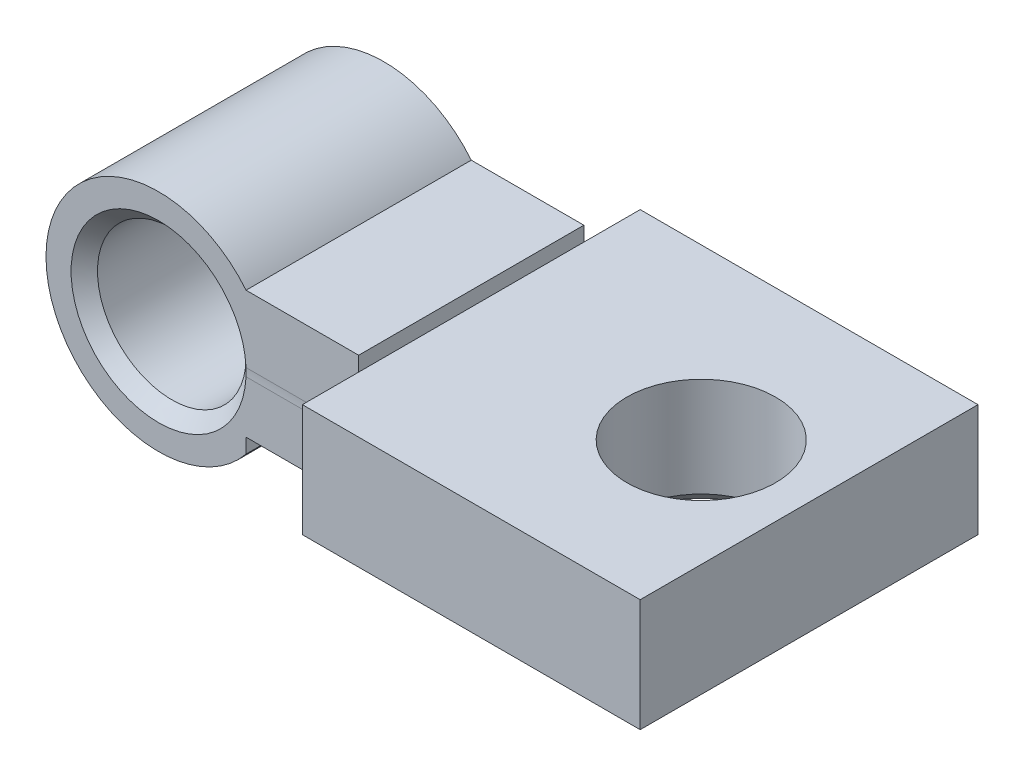
from build123d import *

# Parameters (mm, degrees)
SKETCH_1_R                      = 5
EXTRUDE_1_DEPTH                 = 10
HOLE_WIZARD_G1_16_1_D           = 6.6
HOLE_WIZARD_G1_16_1_DEPTH       = 50
HOLE_WIZARD_G1_16_1_CSINK_D     = 7.773
HOLE_WIZARD_G1_16_1_CSINK_ANGLE = 90
HOLE_WIZARD_G1_16_1_TIP         = 1.982840043
SKETCH_4_W                      = 1.792487356
SKETCH_4_H                      = 9.243284927
CUT_EXTRUDE_1_DEPTH             = 10
EXTRUDE_2_DEPTH                 = 5
SKETCH_6_W                      = 15
SKETCH_6_H                      = 5
EXTRUDE_3_DEPTH                 = 15
HOLE_WIZARD_G1_16_2_D           = 6.6
HOLE_WIZARD_G1_16_2_DEPTH       = 50
HOLE_WIZARD_G1_16_2_CSINK_D     = 7.773
HOLE_WIZARD_G1_16_2_CSINK_ANGLE = 90
HOLE_WIZARD_G1_16_2_TIP         = 1.982840043


with BuildPart() as part:
    # 草图1 → 凸台-拉伸1 (new body)
    with BuildSketch(Plane.XY):
        Circle(SKETCH_1_R)
    extrude(amount=EXTRUDE_1_DEPTH)

    # G1/16 螺纹孔1
    with Locations(Plane.XY.offset(10)):
        with Locations((0, 0)):
            CounterSinkHole(HOLE_WIZARD_G1_16_1_D / 2, HOLE_WIZARD_G1_16_1_CSINK_D / 2, depth=HOLE_WIZARD_G1_16_1_DEPTH, counter_sink_angle=HOLE_WIZARD_G1_16_1_CSINK_ANGLE)
            with Locations((0, 0, -(HOLE_WIZARD_G1_16_1_DEPTH + HOLE_WIZARD_G1_16_1_TIP / 2))):  # 118° drill point
                Cone(0, HOLE_WIZARD_G1_16_1_D / 2, HOLE_WIZARD_G1_16_1_TIP, mode=Mode.SUBTRACT)

    # 草图4 → 切除-拉伸1 (cut)
    with BuildSketch(Plane.XY.offset(10)):
        with Locations((4.778713525, -1.471019051)):
            Rectangle(SKETCH_4_W, SKETCH_4_H)
    extrude(amount=-CUT_EXTRUDE_1_DEPTH, mode=Mode.SUBTRACT)

    # 草图5 → 凸台-拉伸2 (add)
    with BuildSketch(Plane(origin=(3.882469847, 0, 0), x_dir=(0, 0, -1), z_dir=(1, 0, 0))):
        with BuildLine():
            Line((-10, -0.176946718), (-10, -2.5))
            Line((-10, -2.5), (0, -2.5))
            Line((0, -2.5), (0, 3.150623413))
            Line((0, 3.150623413), (-10, 3.150623413))
            Line((-10, 3.150623413), (-10, 0.176946718))
            add(Edge.make_bspline(
                [(-10, 0.176946718), (-9.991943872, 0), (-10, -0.176946718)],
                knots=[-0.045560049, -0.045560049, -0.045560049, 0.045560049, 0.045560049, 0.045560049], degree=2, weights=[1, 1.001038039, 1]))
        make_face()
    extrude(amount=EXTRUDE_2_DEPTH)

    # 草图6 → 凸台-拉伸3 (add)
    with BuildSketch(Plane(origin=(8.882469847, 0, 0), x_dir=(0, 0, -1), z_dir=(1, 0, 0))):
        with Locations((-5, 0)):
            Rectangle(SKETCH_6_W, SKETCH_6_H)
    extrude(amount=EXTRUDE_3_DEPTH)

    # G1/16 螺纹孔2
    with Locations(Plane(origin=(0, -2.5, 0), x_dir=(-1, 0, 0), z_dir=(0, -1, 0))):
        with Locations((-19.093145461, -5)):
            CounterSinkHole(HOLE_WIZARD_G1_16_2_D / 2, HOLE_WIZARD_G1_16_2_CSINK_D / 2, depth=HOLE_WIZARD_G1_16_2_DEPTH, counter_sink_angle=HOLE_WIZARD_G1_16_2_CSINK_ANGLE)
            with Locations((0, 0, -(HOLE_WIZARD_G1_16_2_DEPTH + HOLE_WIZARD_G1_16_2_TIP / 2))):  # 118° drill point
                Cone(0, HOLE_WIZARD_G1_16_2_D / 2, HOLE_WIZARD_G1_16_2_TIP, mode=Mode.SUBTRACT)


solid = part.part
